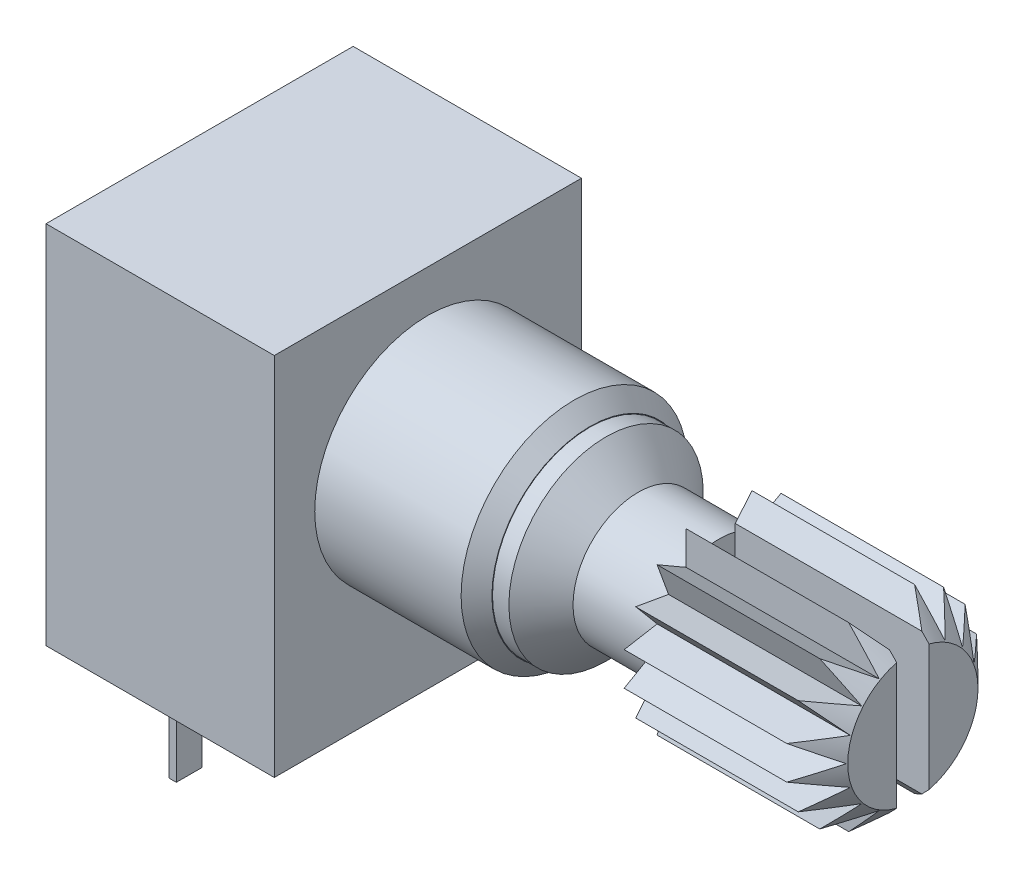
from build123d import *

# Parameters (mm, degrees)
SKETCH2_R                     = 3.811725635
F_18_TEETH_KNURLS_DEPTH       = 5.9944
SKETCH3_W                     = 1
SKETCH3_H                     = 6.35
CUT_EXTRUDE2_DEPTH            = 5.9944
SKETCH4_W                     = 9.4996
SKETCH4_H                     = 11.303
BODY_DEPTH                    = 7.0612
SKETCH6_W                     = 0.2286
SKETCH6_H                     = 0.7874
PINS_PTD901_ONE_SECTION_DEPTH = 3.5


with BuildPart() as part:
    # Sketch1 → Shaft Base (revolve)
    with BuildSketch(Plane.XY):
        Polygon((0, 3.5), (4.52755, 3.5), (5.0038, 3.02375), (5.0038, 0), (0, 0), align=None)
    revolve(axis=Axis((-1.517556918, 0, 0), (1, 0, 0)))

    # Sketch8 → K Style Shaft (revolve)
    with BuildSketch(Plane.XY):
        Polygon((5.0038, 3.00589629), (5.0038, 0), (15, 0), (15, 2.01414629), (14.0348, 2.97934629), (9.0056, 2.97934629), (9.0056, 2.01414629), (6.5024, 2.01414629), (5.51065, 3.00589629), align=None)
    revolve(axis=Axis((-8.258778459, 0, 0), (1, 0, 0)))

    # Sketch2 → 18 Teeth Knurls (cut)
    with BuildSketch(Plane(origin=(15, 0, 0), x_dir=(0, 0, -1), z_dir=(1, 0, 0))):
        Circle(SKETCH2_R)
        Polygon((0, 2.97934629), (0.353893751, 2.007031199), (1.018996445, 2.799669723), (1.018996445, 1.764953616), (1.91508688, 2.282311669), (1.561193129, 1.309996578), (2.580189574, 1.489673145), (1.91508688, 0.69703462), (2.934083325, 0.517358054), (2.03799289, 0), (2.934083325, -0.517358054), (1.91508688, -0.69703462), (2.580189574, -1.489673145), (1.561193129, -1.309996578), (1.91508688, -2.282311669), (1.018996445, -1.764953616), (1.018996445, -2.799669723), (0.353893751, -2.007031199), (0, -2.97934629), (-0.353893751, -2.007031199), (-1.018996445, -2.799669723), (-1.018996445, -1.764953616), (-1.91508688, -2.282311669), (-1.561193129, -1.309996578), (-2.580189574, -1.489673145), (-1.91508688, -0.69703462), (-2.934083325, -0.517358054), (-2.03799289, 0), (-2.934083325, 0.517358054), (-1.91508688, 0.69703462), (-2.580189574, 1.489673145), (-1.561193129, 1.309996578), (-1.91508688, 2.282311669), (-1.018996445, 1.764953616), (-1.018996445, 2.799669723), (-0.353893751, 2.007031199), align=None, mode=Mode.SUBTRACT)
    extrude(amount=-F_18_TEETH_KNURLS_DEPTH, mode=Mode.SUBTRACT)

    # Sketch3 → Cut-Extrude2 (cut)
    with BuildSketch(Plane(origin=(15, 0, 0), x_dir=(0, 0, -1), z_dir=(1, 0, 0))):
        Rectangle(SKETCH3_W, SKETCH3_H)
    extrude(amount=-CUT_EXTRUDE2_DEPTH, mode=Mode.SUBTRACT)

    # Sketch4 → Body (add)
    with BuildSketch(Plane.ZY):
        with Locations((0, -0.8509)):
            Rectangle(SKETCH4_W, SKETCH4_H)
    extrude(amount=BODY_DEPTH)

    # Sketch6 → Pins PTD901 (one section) (add)
    with BuildSketch(Plane.XZ.offset(6.5024)):
        with Locations((-5, -2.5)):
            Rectangle(SKETCH6_W, SKETCH6_H)
        with Locations((-5, 0)):
            Rectangle(SKETCH6_W, SKETCH6_H)
        with Locations((-5, 2.5)):
            Rectangle(SKETCH6_W, SKETCH6_H)
    extrude(amount=PINS_PTD901_ONE_SECTION_DEPTH)


solid = part.part
